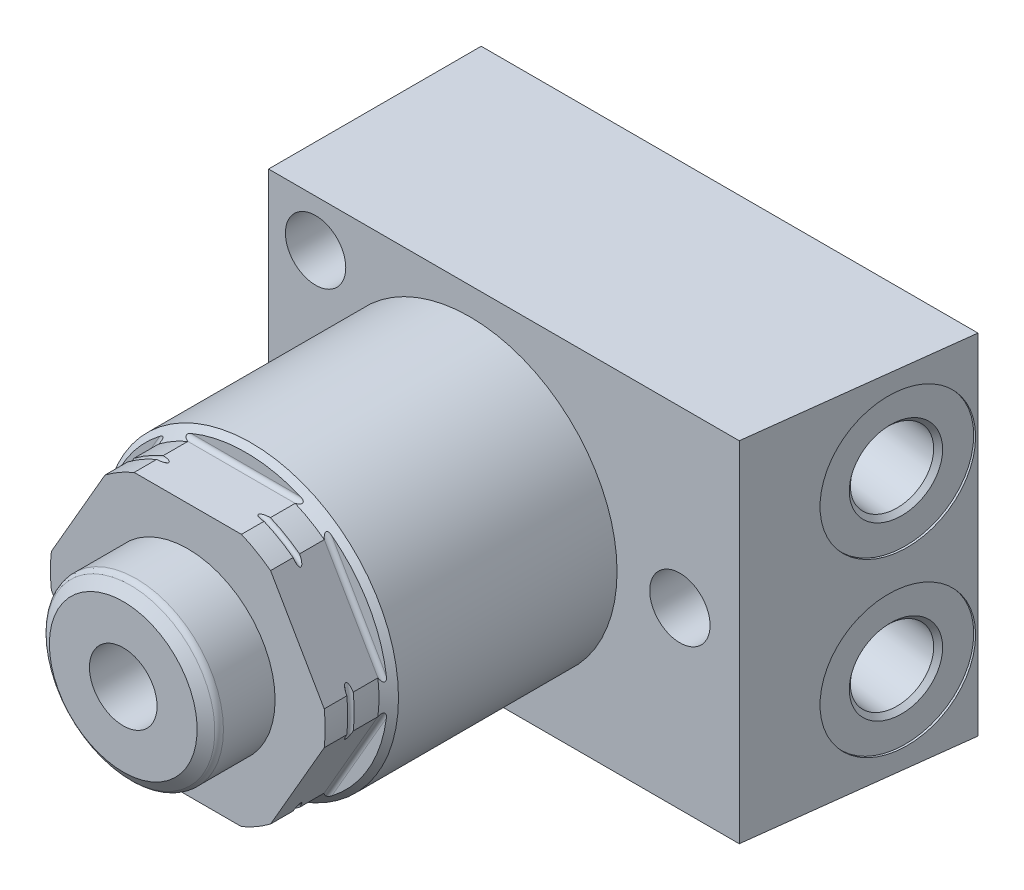
from build123d import *

# Parameters (mm, degrees)
CUT_EXTRUDE1_DEPTH = 18.4117
CIRPATTERN1_COUNT  = 6
EXTRUDE1_DEPTH     = 20.6375
SKETCH4_R          = 4.0005
CUT_EXTRUDE2_DEPTH = 6.0452
HOLE1_D            = 7.1374
HOLE1_DEPTH        = 25.146
LPATTERN1_COUNT    = 2
LPATTERN1_PITCH    = 20.2946


with BuildPart() as part:
    # Sketch1 → Revolve1 (revolve)
    with BuildSketch(Plane(origin=(0, 0, 0), x_dir=(0, 0, -1), z_dir=(1, 0, 0)), mode=Mode.PRIVATE) as revolve1_sk:
        Polygon((0, 0), (0, 13.9954), (-4.6736, 13.9954), (-4.6736, 15.5067), (-8.2804, 15.5067), (-10.1854, 17.4117), (-42.2275, 17.4117), (-43.3832, 16.256), (-49.7332, 16.256), (-49.7332, 0), align=None)
    revolve(revolve1_sk.sketch.rotate(Axis((0, 0, 0), (0, 0, -1)), 90), axis=Axis((0, 0, 0), (0, 0, -1)))  # turned: the seam where the file's is

    # Sketch2 → Cut-Extrude1 (cut, symmetric)
    with BuildSketch(Plane(origin=(0, 0, 0), x_dir=(0, 0, -1), z_dir=(1, 0, 0))):
        with BuildLine():
            Line((-49.7332, 14.96695), (-43.3832, 14.96695))
            ThreePointArc((-43.3832, 14.96695), (-43.023989755, 15.115739755), (-42.8752, 15.47495))
            Line((-42.8752, 15.47495), (-42.8752, 18.14195))
            Line((-42.8752, 18.14195), (-49.7332, 18.14195))
            Line((-49.7332, 18.14195), (-49.7332, 14.96695))
        make_face()
    cut_extrude1 = extrude(amount=CUT_EXTRUDE1_DEPTH, both=True, mode=Mode.SUBTRACT)

    # CirPattern1: Cut-Extrude1 ×6 about axis
    cirpattern1_axis = Axis((0, 0, 0), (0, 0, 1))
    for i in range(1, CIRPATTERN1_COUNT):
        add(cut_extrude1.rotate(cirpattern1_axis, i * 360 / CIRPATTERN1_COUNT), mode=Mode.SUBTRACT)

    # Sketch6 → Extrude1 (add, symmetric)
    with BuildSketch(Plane(origin=(0, 0, 0), x_dir=(1, 0, 0), z_dir=(0, 1, 0))):
        Polygon((-23.7998, -16.383), (31.862859432, -16.383), (34.9504, 8.763), (-23.7998, 8.763), align=None)
    extrude(amount=EXTRUDE1_DEPTH, both=True)

    # Sketch3 → Revolve2 (revolve)
    with BuildSketch(Plane(origin=(0, 0, 0), x_dir=(0, 0, -1), z_dir=(1, 0, 0)), mode=Mode.PRIVATE) as revolve2_sk:
        with BuildLine():
            Line((-57.3659, 0), (-57.3659, 8.7376))
            Line((-57.3659, 8.7376), (-56.510407199, 9.97462236))
            ThreePointArc((-56.510407199, 9.97462236), (-56.219304442, 10.232167854), (-55.8419, 10.3251))
            Line((-55.8419, 10.3251), (-49.7332, 10.3251))
            Line((-49.7332, 10.3251), (-49.7332, 0))
            Line((-49.7332, 0), (-57.3659, 0))
        make_face()
    revolve(revolve2_sk.sketch.rotate(Axis((0, 0, 0), (0, 0, 1)), 90), axis=Axis((0, 0, 0), (0, 0, 1)))  # turned: the seam where the file's is

    # Sketch4 → Cut-Extrude2 (cut)
    with BuildSketch(Plane.XY.offset(57.3659)):
        Circle(SKETCH4_R)
    extrude(amount=-CUT_EXTRUDE2_DEPTH, mode=Mode.SUBTRACT)

    # Sketch5 → Cut-Revolve1 (revolve, cut)
    with BuildSketch(Plane(origin=(0, 0, 0), x_dir=(0, 0, -1), z_dir=(1, 0, 0)), mode=Mode.PRIVATE) as cut_revolve1_sk:
        with BuildLine():
            Line((-47.0662, 19.431), (-47.0662, 16.256))
            ThreePointArc((-47.0662, 16.256), (-46.6852, 15.875), (-46.3042, 16.256))
            Line((-46.3042, 16.256), (-46.3042, 19.431))
            Line((-46.3042, 19.431), (-47.0662, 19.431))
        make_face()
    revolve(cut_revolve1_sk.sketch.rotate(Axis((0, 0, 0), (0, 0, 1)), 97.029074864), axis=Axis((0, 0, 0), (0, 0, 1)), mode=Mode.SUBTRACT)  # turned: the seam where the file's is

    # Hole1
    with Locations(Plane.XY.offset(16.383)):
        with Locations((-18.2372, 15.0876), (-18.2372, -15.0876), (24.8412, 0)):
            Hole(HOLE1_D / 2, depth=HOLE1_DEPTH)

    # Sketch9 → Cut-Revolve2 (revolve, cut)
    with BuildSketch(Plane(origin=(0, -10.1473, 0), x_dir=(-1, 0, 0), z_dir=(0, 1, 0)), mode=Mode.PRIVATE) as cut_revolve2_sk:
        Polygon((-32.907382327, 7.876043686), (-32.655275605, 7.845088873), (-33.057688177, 4.56770148), (-32.593269167, 3.973272255), (-22.635053628, 2.750557133), (-23.173667378, -1.636099839), (-33.913413757, -0.317424796), align=None)
    cut_revolve2 = revolve(cut_revolve2_sk.sketch.rotate(Axis((33.913413757, -10.1473, -0.317424796), (-0.992546152, 0, -0.121869343)), 180), axis=Axis((33.913413757, -10.1473, -0.317424796), (-0.992546152, 0, -0.121869343)), mode=Mode.SUBTRACT)  # turned: the seam where the file's is

    # LPattern1: Cut-Revolve2 ×2
    with Locations(*[(0, i * LPATTERN1_PITCH, 0) for i in range(1, LPATTERN1_COUNT)]):
        add(cut_revolve2, mode=Mode.SUBTRACT)


solid = part.part
